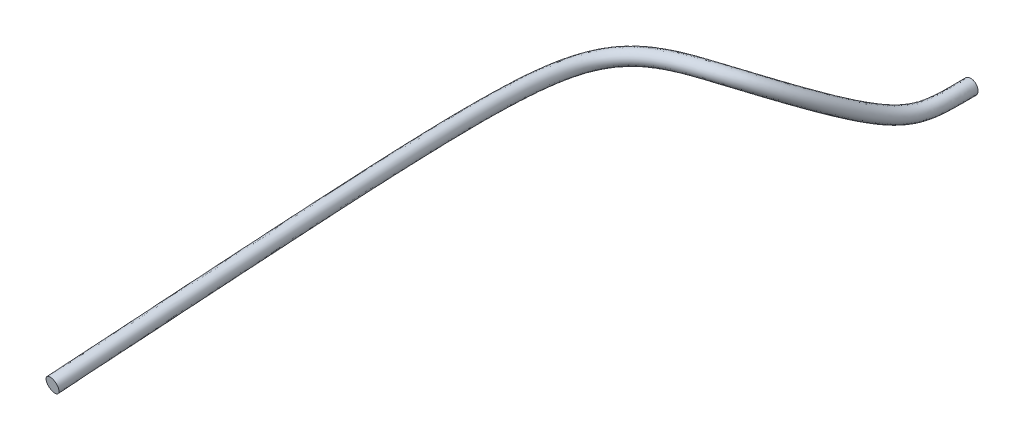
from build123d import *

# Parameters (mm, degrees)
SKETCH1_R = 1.15


with BuildPart() as part:
    # Sweep1: sweep along a curve in space
    with BuildLine() as sweep1_path:
        add(Edge.make_bspline(
            [(0, 0, 0), (0, 0, 5.554280497), (-0.925650591, -1.475521411, 10.025563592), (-7.968179119, 12.994599316, 30.668290831), (-32.695089228, 5.254873483, 29.033980347), (-25.718134594, 10.067456397, 61.185081988), (-31.99885467, -0.11505787, 113.90153164)],
            knots=[0, 0, 0, 0, 0.255984711, 0.525951588, 0.698297396, 1, 1, 1, 1], degree=3))
    # Sketch1 → Sweep1 (sweep)
    with BuildSketch(Plane.XY):
        Circle(SKETCH1_R)
    sweep(path=sweep1_path.line)


solid = part.part
